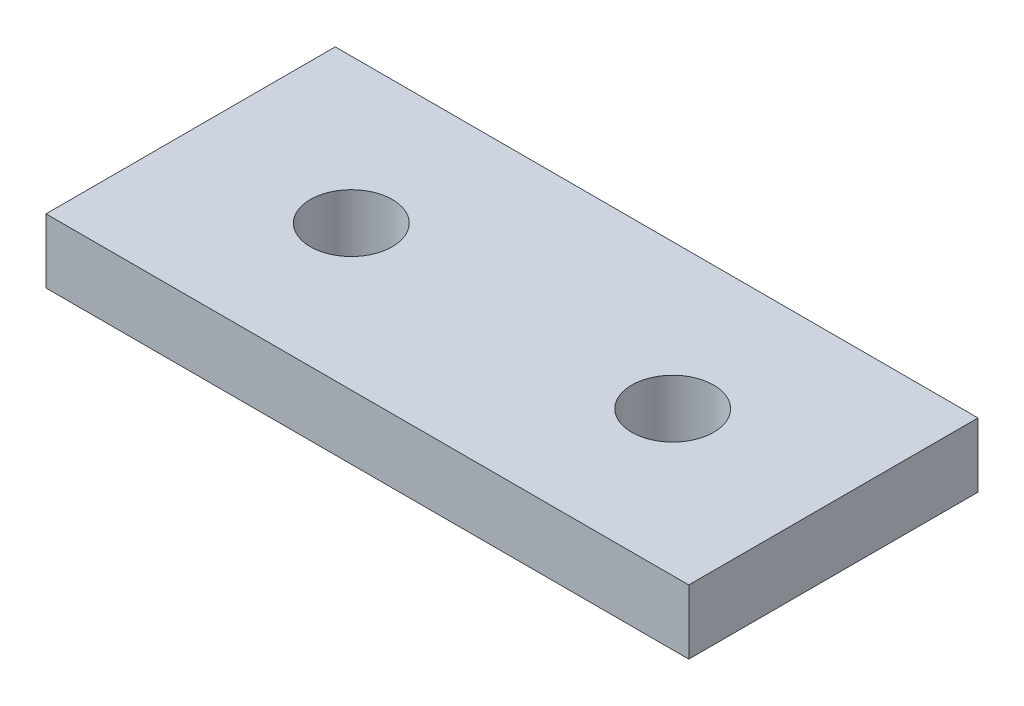
from build123d import *

# Parameters (mm, degrees)
SKETCH1_W           = 40
SKETCH1_H           = 18
SKETCH1_R           = 2.55
BOSS_EXTRUDE1_DEPTH = 4


with BuildPart() as part:
    # Sketch1 → Boss-Extrude1 (new body)
    with BuildSketch(Plane(origin=(0, 0, 0), x_dir=(1, 0, 0), z_dir=(0, 1, 0))):
        Rectangle(SKETCH1_W, SKETCH1_H)
        with Locations((-10, 0)):
            Circle(SKETCH1_R, mode=Mode.SUBTRACT)
        with Locations((10, 0)):
            Circle(SKETCH1_R, mode=Mode.SUBTRACT)
    extrude(amount=BOSS_EXTRUDE1_DEPTH)


solid = part.part
